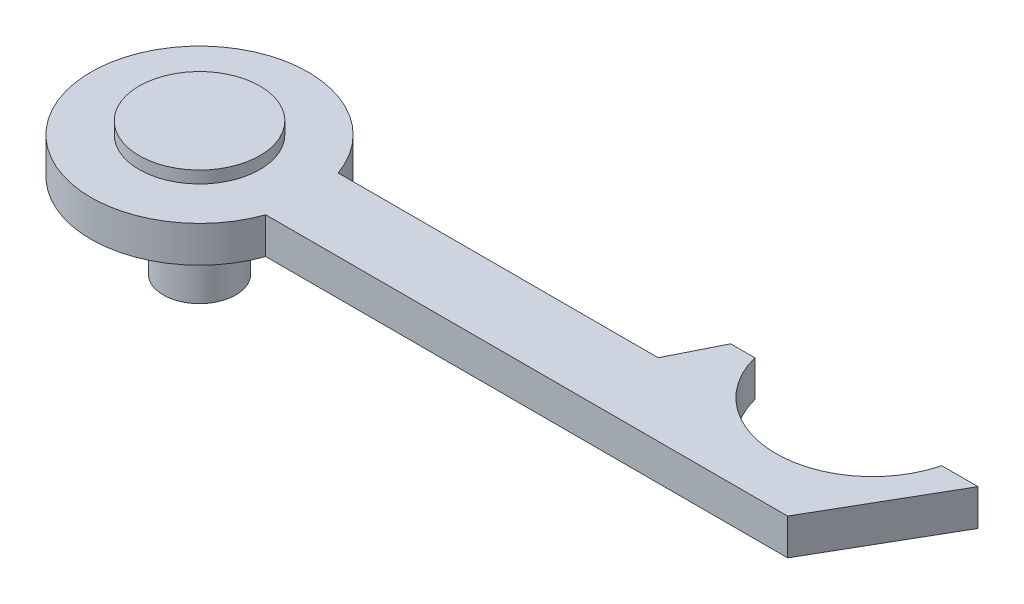
from build123d import *

# Parameters (mm, degrees)
IZIM1_R                     = 9
IZIM1_R_2                   = 3
Y_KSEKLIK_EKSTR_ZYON1_DEPTH = 3
Y_KSEKLIK_EKSTR_ZYON2_DEPTH = 3


with BuildPart() as part:
    # Çizim1 → Yükseklik-Ekstrüzyon1 (new body)
    with BuildSketch(Plane(origin=(0, 0, 0), x_dir=(1, 0, 0), z_dir=(0, 1, 0))):
        Circle(IZIM1_R)
        Circle(IZIM1_R_2, mode=Mode.SUBTRACT)
    extrude(amount=Y_KSEKLIK_EKSTR_ZYON1_DEPTH)

    # Çizim3 → Yükseklik-Ekstrüzyon2 (add)
    with BuildSketch(Plane(origin=(0, 3, 0), x_dir=(1, 0, 0), z_dir=(0, 1, 0))):
        with BuildLine():
            Line((8.485281374, 3), (35, 3))
            Line((35, 3), (37, 7))
            Line((37, 7), (39, 7))
            ThreePointArc((39, 7), (46.745966692, 1), (54.491933385, 7))
            Line((54.491933385, 7), (57.491933385, 7))
            Line((57.491933385, 7), (51.718430693, -3))
            Line((51.718430693, -3), (8.485281374, -3))
            ThreePointArc((8.485281374, -3), (9, 0), (8.485281374, 3))
        make_face()
    extrude(amount=-Y_KSEKLIK_EKSTR_ZYON2_DEPTH)


with BuildPart() as body_2:
    # Çizim5 → Döndür1 (revolve)
    with BuildSketch(Plane.XY):
        Polygon((0, 3), (0, -7), (3, -7), (3, 3), (5, 3), (5, 4), (0, 4), align=None)
    revolve(axis=Axis((0, 3, 0), (0, -1, 0)))


solid = Compound([part.part, body_2.part])
